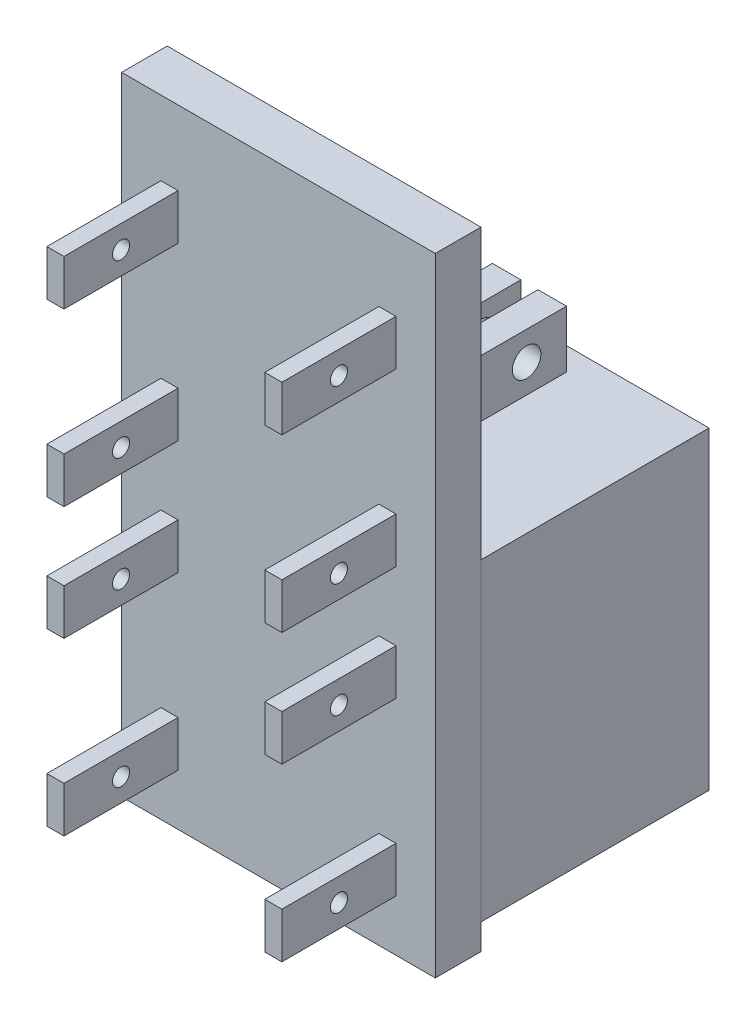
from build123d import *

# Parameters (mm, degrees)
BOSS_EXTRUDE1_DEPTH     = 40
SKETCH2_R               = 2.5
CUT_EXTRUDE1_DEPTH      = 13
CUT_EXTRUDE2_DEPTH      = 10
SKETCH6_W               = 55
SKETCH6_H               = 110
BOSS_EXTRUDE8_DEPTH     = 8
SKETCH7_W               = 4
SKETCH7_H               = 10
CUT_EXTRUDE3_DEPTH      = 13
SKETCH11_W              = 3
SKETCH11_H              = 8
BOSS_EXTRUDE9_DEPTH     = 20
SKETCH12_R              = 1.5
CUT_EXTRUDE4_DEPTH      = 41.2
MIRROR3_COPY_1_SKETCH_R = 1.5
MIRROR3_COPY_1_DEPTH    = 41.2


with BuildPart() as part:
    # Sketch1 → Boss-Extrude1 (new body)
    with BuildSketch(Plane.XY):
        Polygon((-21, 0), (21, 0), (21, 42), (1.5, 42), (1.5, 58.5), (6.5, 58.5), (6.5, 48.5), (27.5, 48.5), (27.5, -6.5), (-27.5, -6.5), (-27.5, 48.5), (-6.5, 48.5), (-6.5, 58.5), (-1.5, 58.5), (-1.5, 42), (-21, 42), align=None)
    extrude(amount=BOSS_EXTRUDE1_DEPTH)

    # Sketch2 → Cut-Extrude1 (cut)
    with BuildSketch(Plane.ZY.offset(6.5)):
        with Locations((11, 53.5)):
            Circle(SKETCH2_R)
        with Locations((29, 53.5)):
            Circle(SKETCH2_R)
    extrude(amount=-CUT_EXTRUDE1_DEPTH, mode=Mode.SUBTRACT)

    # Sketch3 → Cut-Extrude2 (cut)
    with BuildSketch(Plane(origin=(0, 0, 0), x_dir=(-1, 0, 0), z_dir=(0, 0, -1))):
        with BuildLine():
            Line((20.5, -6.5), (19.170549473, -5.005824209))
            ThreePointArc((19.170549473, -5.005824209), (18.157592064, -4.262982703), (16.929285786, -4))
            Line((16.929285786, -4), (-3.929285786, -4))
            ThreePointArc((-3.929285786, -4), (-5.157592064, -4.262982703), (-6.170549473, -5.005824209))
            Line((-6.170549473, -5.005824209), (-7.5, -6.5))
            Line((-7.5, -6.5), (20.5, -6.5))
        make_face()
    extrude(amount=-CUT_EXTRUDE2_DEPTH, mode=Mode.SUBTRACT)

    # Sketch7 → Cut-Extrude3 (cut)
    with BuildSketch(Plane.ZY.offset(6.5)):
        with Locations((38, 53.5)):
            Rectangle(SKETCH7_W, SKETCH7_H)
        with Locations((2, 53.5)):
            Rectangle(SKETCH7_W, SKETCH7_H)
    extrude(amount=-CUT_EXTRUDE3_DEPTH, mode=Mode.SUBTRACT)


with BuildPart() as body_2:
    # Sketch6 → Boss-Extrude8 (new body)
    with BuildSketch(Plane.XY.offset(40)):
        with Locations((0, 44)):
            Rectangle(SKETCH6_W, SKETCH6_H)
    extrude(amount=BOSS_EXTRUDE8_DEPTH)

    # Sketch11 → Boss-Extrude9 (add)
    with BuildSketch(Plane.XY.offset(48)):
        with Locations((-19.1, 82)):
            Rectangle(SKETCH11_W, SKETCH11_H)
        with Locations((-19.1, 2)):
            Rectangle(SKETCH11_W, SKETCH11_H)
        with Locations((19.1, 2)):
            Rectangle(SKETCH11_W, SKETCH11_H)
        with Locations((19.1, 82)):
            Rectangle(SKETCH11_W, SKETCH11_H)
        with Locations((19.1, 52)):
            Rectangle(SKETCH11_W, SKETCH11_H)
        with Locations((-19.1, 52)):
            Rectangle(SKETCH11_W, SKETCH11_H)
        with Locations((19.1, 32)):
            Rectangle(SKETCH11_W, SKETCH11_H)
        with Locations((-19.1, 32)):
            Rectangle(SKETCH11_W, SKETCH11_H)
    extrude(amount=BOSS_EXTRUDE9_DEPTH)

    # Sketch12 → Cut-Extrude4 (cut)
    with BuildSketch(Plane.ZY.offset(20.6)):
        with Locations((58, 82)):
            Circle(SKETCH12_R)
    cut_extrude4 = extrude(amount=-CUT_EXTRUDE4_DEPTH, mode=Mode.SUBTRACT)

    # Mirror1: Cut-Extrude4 across plane
    add(cut_extrude4.mirror(Plane(origin=(0, 67, 0), x_dir=(0, 0, 1), z_dir=(0, -1, 0))), mode=Mode.SUBTRACT)

    # Mirror2: Cut-Extrude4 across plane
    add(cut_extrude4.mirror(Plane(origin=(0, 42, 0), x_dir=(0, 0, 1), z_dir=(0, -1, 0))), mode=Mode.SUBTRACT)

    # Mirror3 copy 1 sketch → Mirror3 copy 1 (cut)
    with BuildSketch(Plane(origin=(-20.6, -50, 0), x_dir=(0, 0, 1), z_dir=(-1, 0, 0))):
        with Locations((58, 82)):
            Circle(MIRROR3_COPY_1_SKETCH_R)
    extrude(amount=-MIRROR3_COPY_1_DEPTH, mode=Mode.SUBTRACT)


solid = Compound([part.part, body_2.part])
